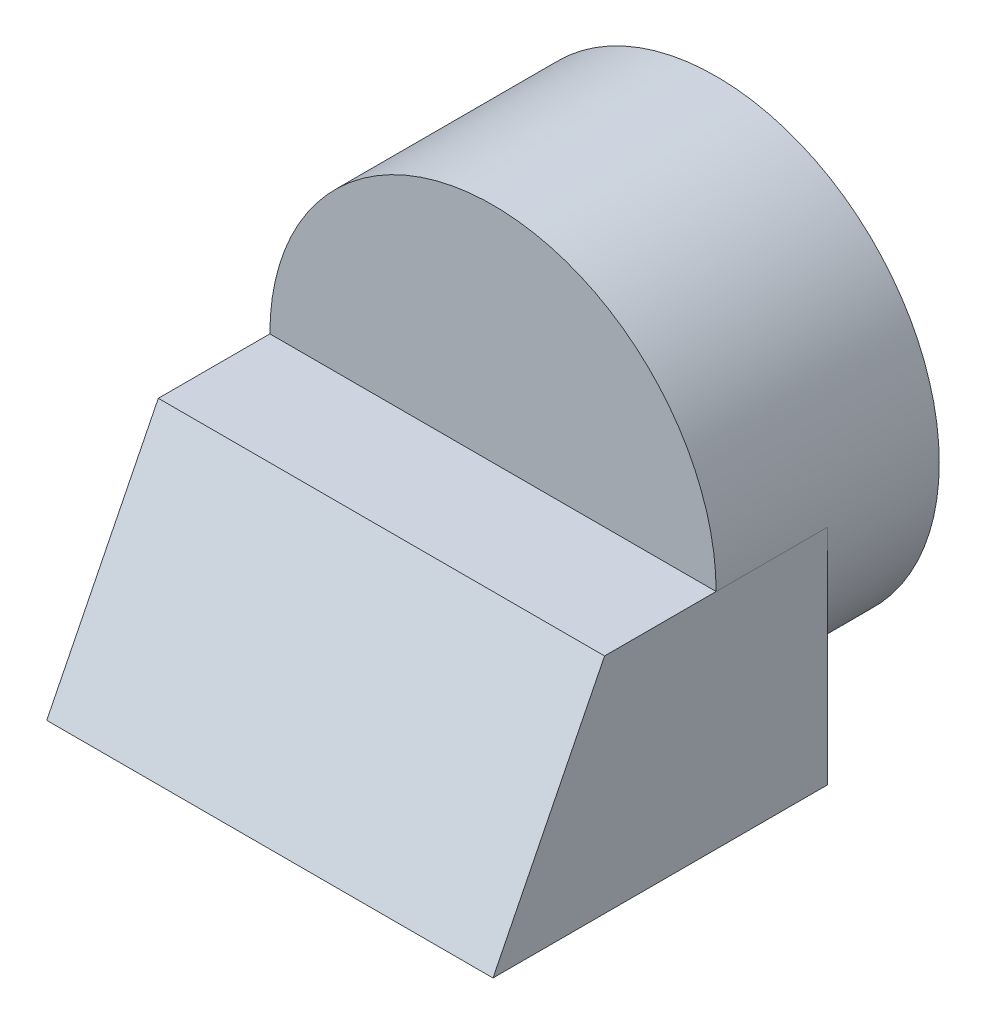
from build123d import *

# Parameters (mm, degrees)
SKETCH1_W           = 4
SKETCH1_H           = 4
BOSS_EXTRUDE1_DEPTH = 4
CUT_EXTRUDE1_DEPTH  = 4
CUT_EXTRUDE2_DEPTH  = 4
CUT_EXTRUDE3_DEPTH  = 1


with BuildPart() as part:
    # Sketch1 → Boss-Extrude1 (new body)
    with BuildSketch(Plane(origin=(0, 0, 0), x_dir=(1, 0, 0), z_dir=(0, 1, 0))):
        Rectangle(SKETCH1_W, SKETCH1_H)
    extrude(amount=BOSS_EXTRUDE1_DEPTH)

    # Sketch2 → Cut-Extrude1 (cut)
    with BuildSketch(Plane.XY.offset(2)):
        with BuildLine():
            Line((-2, 4), (-2, 2))
            ThreePointArc((-2, 2), (-1.414213562, 3.414213562), (0, 4))
            Line((0, 4), (-2, 4))
        make_face()
        with BuildLine():
            Line((2, 4), (0, 4))
            ThreePointArc((0, 4), (1.414213562, 3.414213562), (2, 2))
            Line((2, 2), (2, 4))
        make_face()
    extrude(amount=-CUT_EXTRUDE1_DEPTH, mode=Mode.SUBTRACT)

    # Sketch3 → Cut-Extrude2 (cut)
    with BuildSketch(Plane.ZY.offset(2)):
        Polygon((2, 0), (1, 2), (0, 2), (0, 4), (2, 4), align=None)
    extrude(amount=-CUT_EXTRUDE2_DEPTH, mode=Mode.SUBTRACT)

    # Sketch4 → Cut-Extrude3 (cut)
    with BuildSketch(Plane(origin=(0, 0, -2), x_dir=(-1, 0, 0), z_dir=(0, 0, -1))):
        with BuildLine():
            ThreePointArc((0, 0), (-1.414213562, 0.585786438), (-2, 2))
            Line((-2, 2), (-2, 0))
            Line((-2, 0), (0, 0))
        make_face()
        with BuildLine():
            ThreePointArc((2, 2), (1.414213562, 0.585786438), (0, 0))
            Line((0, 0), (2, 0))
            Line((2, 0), (2, 2))
        make_face()
    extrude(amount=-CUT_EXTRUDE3_DEPTH, mode=Mode.SUBTRACT)


solid = part.part
